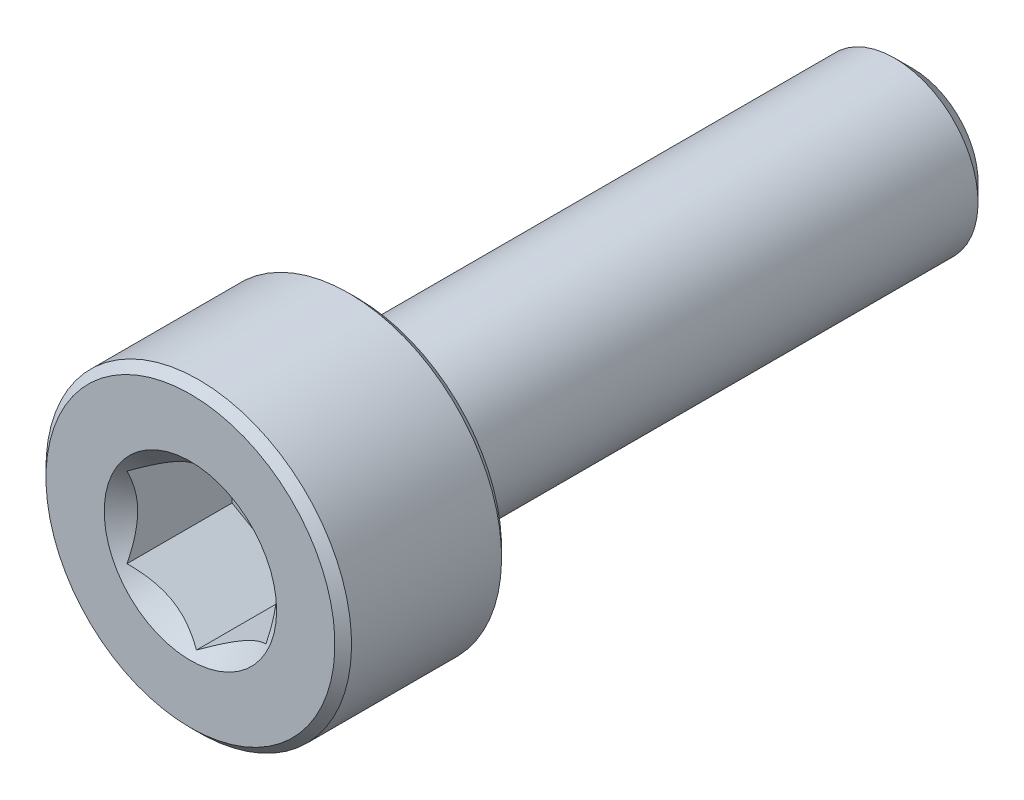
from build123d import *

# Parameters (mm, degrees)
CUT_EXTRUDE1_DEPTH     = 2
SKETCH4_R              = 1.551628848
CUT_EXTRUDE2_DEPTH     = 1.5
CUT_EXTRUDE2_DRAFT     = -45
SPLIT1_SURFACE_1_BACK  = 16.149
SPLIT1_SURFACE_1_DEPTH = 32.298
SPLIT1_SURFACE_2_BACK  = 16.149
SPLIT1_SURFACE_2_DEPTH = 32.298


with BuildPart() as part:
    # Sketch2 → Revolve1 (revolve)
    with BuildSketch(Plane(origin=(0, 0, 0), x_dir=(0, 0, -1), z_dir=(1, 0, 0))):
        with BuildLine():
            Line((-6.5, 0), (-6.5, 2.6))
            Line((-6.5, 2.6), (-6.35, 2.75))
            Line((-6.35, 2.75), (-3.65, 2.75))
            Line((-3.65, 2.75), (-3.5, 2.6))
            Line((-3.5, 2.6), (-3.5, 1.65))
            ThreePointArc((-3.5, 1.65), (-3.456066017, 1.543933983), (-3.35, 1.5))
            Line((-3.35, 1.5), (6.175240474, 1.5))
            Line((6.175240474, 1.5), (6.5, 1.175240474))
            Line((6.5, 1.175240474), (6.5, 0))
            Line((6.5, 0), (-6.5, 0))
        make_face()
    revolve(axis=Axis((0, 0, -6.5), (0, 0, 1)))

    # Sketch3 → Cut-Extrude1 (cut)
    with BuildSketch(Plane.XY.offset(6.5)):
        Polygon((1.25, -0.721687836), (1.25, 0.721687836), (0, 1.443375673), (-1.25, 0.721687836), (-1.25, -0.721687836), (0, -1.443375673), align=None)
    extrude(amount=-CUT_EXTRUDE1_DEPTH, mode=Mode.SUBTRACT)


with BuildPart() as cut_extrude2_tool:
    # Sketch4 → Cut-Extrude2 (with draft: the straight prism first)
    with BuildSketch(Plane.XY.offset(6.5)):
        Circle(SKETCH4_R)
    extrude(amount=-CUT_EXTRUDE2_DEPTH)
    # Cut-Extrude2: the draft: its side faces are tilted about the plane it starts from
    cut_extrude2_sides = [cut_extrude2_tool.faces().sort_by_distance(p)[0] for p in [
        (-1.551628848, 0, 5.75),
    ]]
    draft(cut_extrude2_sides, Plane.XY.offset(6.5), CUT_EXTRUDE2_DRAFT)


with BuildPart() as part_1:
    add(part.part)

    # Cut-Extrude2: cut by cut_extrude2_tool
    add(cut_extrude2_tool.part, mode=Mode.SUBTRACT)


with BuildPart() as body_2:
    # Split1: the piece behind the surface
    add(part_1.part)
    # Split1 surface: a surface, the sketch's curves swept straight by 32.298 mm
    with BuildLine(Plane(origin=(0, 0, 0), x_dir=(0, 0, -1), z_dir=(1, 0, 0)).offset(-SPLIT1_SURFACE_1_BACK), mode=Mode.PRIVATE) as split1_surface_1_path:
        Line((-3.35, -2.75), (-3.35, 2.75))
    split1_surface_1 = Shell.extrude(split1_surface_1_path.wire(), (1 * SPLIT1_SURFACE_1_DEPTH, 0 * SPLIT1_SURFACE_1_DEPTH, 0 * SPLIT1_SURFACE_1_DEPTH))
    split(bisect_by=split1_surface_1, keep=Keep.BOTTOM)


with BuildPart() as part_2:
    add(part_1.part)

    # Split1: split by a surface, the side it looks to stays
    # Split1 surface: a surface, the sketch's curves swept straight by 32.298 mm
    with BuildLine(Plane(origin=(0, 0, 0), x_dir=(0, 0, -1), z_dir=(1, 0, 0)).offset(-SPLIT1_SURFACE_2_BACK), mode=Mode.PRIVATE) as split1_surface_2_path:
        Line((-3.35, -2.75), (-3.35, 2.75))
    split1_surface_2 = Shell.extrude(split1_surface_2_path.wire(), (1 * SPLIT1_SURFACE_2_DEPTH, 0 * SPLIT1_SURFACE_2_DEPTH, 0 * SPLIT1_SURFACE_2_DEPTH))
    split(bisect_by=split1_surface_2, keep=Keep.TOP)

    # Sketch8 → Revolve2 (revolve)
    with BuildSketch(Plane(origin=(0, 0, 0), x_dir=(0, 0, -1), z_dir=(1, 0, 0)), mode=Mode.PRIVATE) as revolve2_sk:
        Polygon((-3.5, 0), (-3.5, 1.5), (-3.35, 1.5), (-2.483974596, 0), align=None)
    revolve(revolve2_sk.sketch.rotate(Axis((0, 0, 2.483974596), (0, 0, 1)), 180), axis=Axis((0, 0, 2.483974596), (0, 0, 1)))


solid = Compound([body_2.part, part_2.part])
